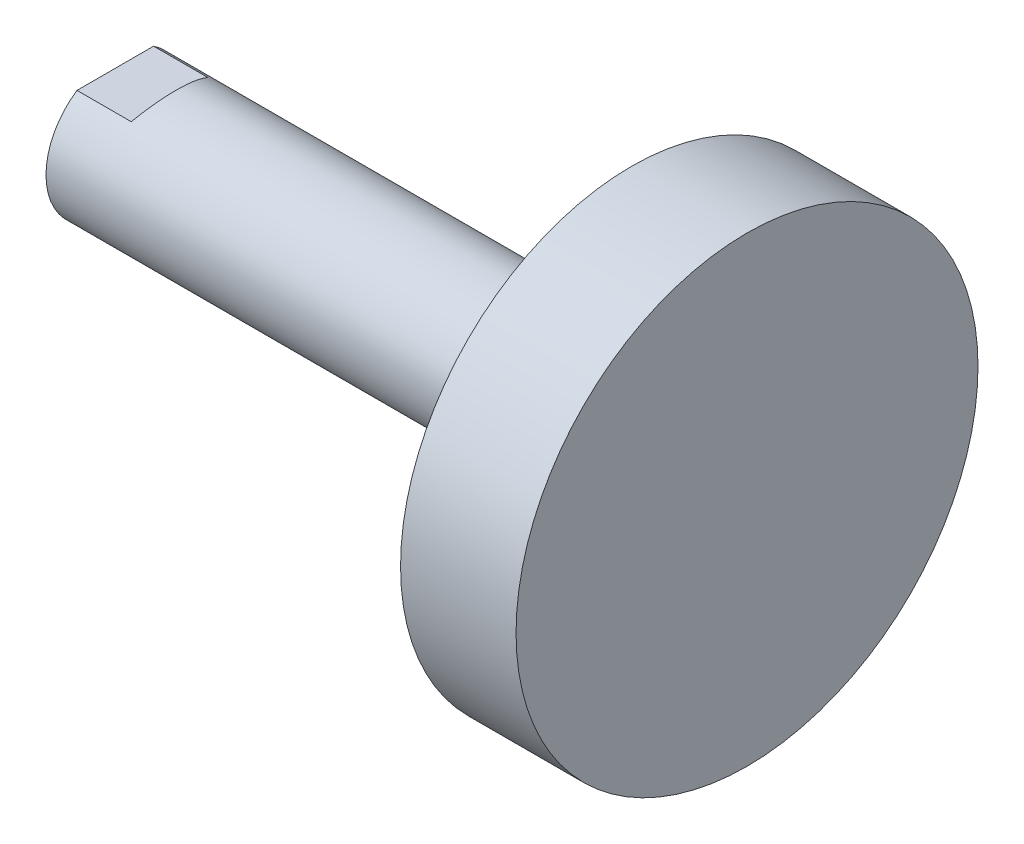
from build123d import *

# Parameters (mm, degrees)
SKIZZE1_W                            = 54.7
SKIZZE1_H                            = 6
SKIZZE2_W                            = 10
SKIZZE2_H                            = 20
SCHNITT_LINEAR_AUSTRAGEN1_DEPTH      = 12
SCHNITT_LINEAR_AUSTRAGEN1_DEPTH_BACK = 12


with BuildPart() as part:
    # Skizze1 → Rotation1 (revolve)
    with BuildSketch(Plane.XY):
        with Locations((21.25, 3)):
            Rectangle(SKIZZE1_W, SKIZZE1_H)
    revolve(axis=Axis((48.6, 0, 0), (-1, 0, 0)))

    # Skizze2 → Rotation2 (revolve)
    with BuildSketch(Plane.XY):
        with Locations((43.6, 10)):
            Rectangle(SKIZZE2_W, SKIZZE2_H)
    revolve(axis=Axis((48.6, 0, 0), (-1, 0, 0)))

    # Skizze3 → Schnitt-Linear austragen1 (cut, two sides: drawn at the far end of the back side and taken through both)
    with BuildSketch(Plane.XY.offset(-SCHNITT_LINEAR_AUSTRAGEN1_DEPTH_BACK)):
        Polygon((-36.2, -16), (4.950852961, -16), (-1.4, -5), (-6.1, -5), (-6.1, -10), (-30.1, -10), (-30.1, 10), (-6.1, 10), (-6.1, 5), (-1.4, 5), (4.950852961, 16), (-36.2, 16), align=None)
    extrude(amount=SCHNITT_LINEAR_AUSTRAGEN1_DEPTH + SCHNITT_LINEAR_AUSTRAGEN1_DEPTH_BACK, mode=Mode.SUBTRACT)

    # Skizze4 → Schnitt-Rotation1 (revolve, cut)
    with BuildSketch(Plane.XY):
        Polygon((-6.1, 0), (-6.1, 4.8), (-5.5, 4.2), (-2.8, 4.2), (-2.8, 4), (-2.1235, 3.3235), (13.9, 3.3235), (15.81882362, 0), align=None)
    revolve(axis=Axis((15.81882362, 0, 0), (-1, 0, 0)), mode=Mode.SUBTRACT)


solid = part.part
